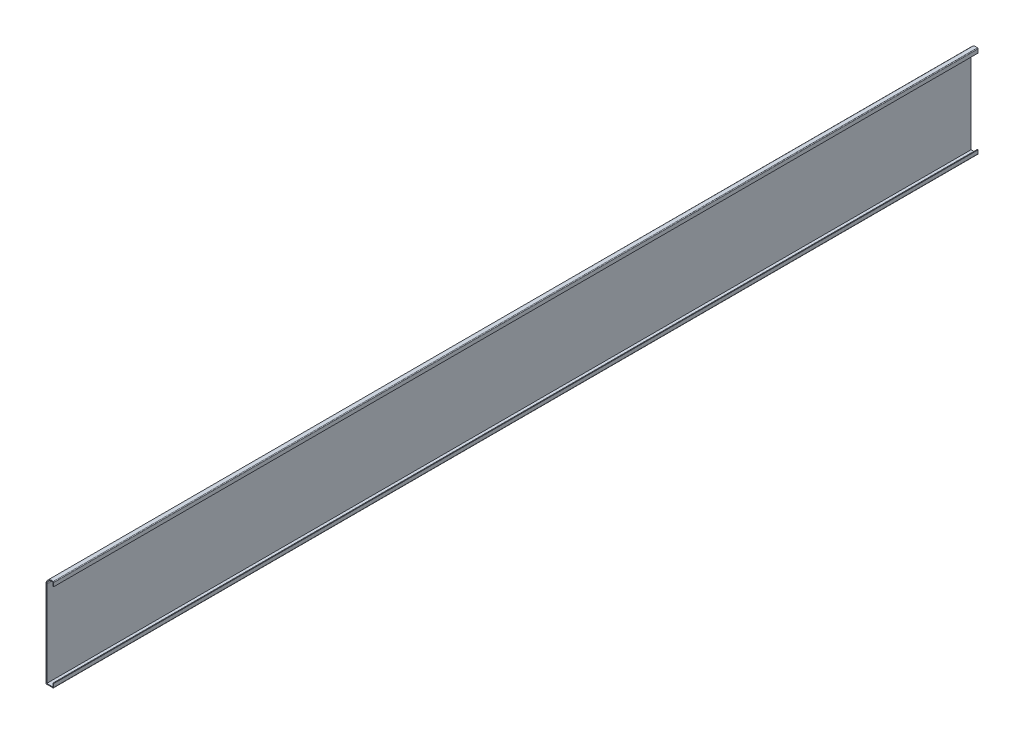
from build123d import *

# Parameters (mm, degrees)
EXTRUDE_THIN1_DEPTH = 1524
FILLET1_R           = 1.27


with BuildPart() as part:
    # Sketch1 → Extrude-Thin1 (new body)
    with BuildSketch(Plane.XY):
        with BuildLine():
            Line((0, 6.858), (0, 0))
            Line((0, 0), (-12.7, 0))
            Line((-12.7, 0), (-12.7, 142.875))
            ThreePointArc((-12.7, 142.875), (-8.674261314, 150.652129933), (0, 151.855256121))
            Line((0, 151.855256121), (0, 144.997256121))
            Line((0, 144.997256121), (-1.27, 144.997256121))
            Line((-1.27, 144.997256121), (-1.27, 150.907185257))
            ThreePointArc((-1.27, 150.907185257), (-8.29453367, 149.350754782), (-11.43, 142.875))
            Line((-11.43, 142.875), (-11.43, 1.27))
            Line((-11.43, 1.27), (-1.27, 1.27))
            Line((-1.27, 1.27), (-1.27, 6.858))
            Line((-1.27, 6.858), (0, 6.858))
        make_face()
    extrude(amount=-EXTRUDE_THIN1_DEPTH)

    # Fillet1
    fillet1_edges = [part.edges().sort_by_distance(p)[0] for p in [
        (0, 0, -762),
        (-12.7, 0, -762),
        (0, 151.855256121, -762),
    ]]
    fillet(fillet1_edges, radius=FILLET1_R)


solid = part.part
